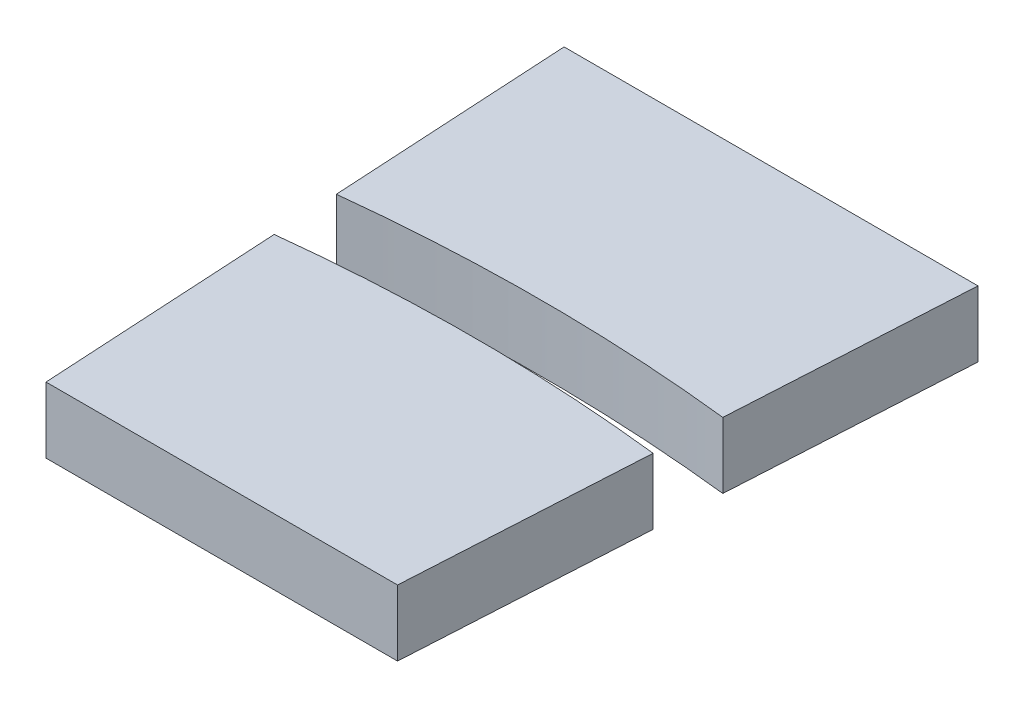
from build123d import *

# Parameters (mm, degrees)
BOSS_EXTRUDE1_DEPTH     = 3
CUT_EXTRUDE1_DEPTH      = 1
CUT_EXTRUDE1_DEPTH_BACK = 4


with BuildPart() as part:
    # Sketch1 → Boss-Extrude1 (new body)
    with BuildSketch(Plane(origin=(0, 0, 0), x_dir=(1, 0, 0), z_dir=(0, 1, 0))):
        Polygon((-9.419602878, 89.5), (-8, 64.5), (0, 64.5), (0, 89.5), align=None)
    boss_extrude1 = extrude(amount=BOSS_EXTRUDE1_DEPTH)

    # Mirror1: Boss-Extrude1 across plane
    add(boss_extrude1.mirror(Plane(origin=(0, 0, 0), x_dir=(0, 0, 1), z_dir=(1, 0, 0))))

    # Sketch2 → Cut-Extrude1 (cut, two sides)
    with BuildSketch(Plane(origin=(0, 3, 0), x_dir=(1, 0, 0), z_dir=(0, 1, 0))) as cut_extrude1_sk:
        with BuildLine():
            Line((-8.625135555, 75.508986463), (-8.795480151, 78.508850004))
            ThreePointArc((-8.795480151, 78.508850004), (0, 79), (8.795480151, 78.508850004))
            Line((8.795480151, 78.508850004), (8.625135555, 75.508986463))
            ThreePointArc((8.625135555, 75.508986463), (0, 76), (-8.625135555, 75.508986463))
        make_face()
    extrude(amount=CUT_EXTRUDE1_DEPTH, mode=Mode.SUBTRACT)
    extrude(cut_extrude1_sk.sketch, amount=-CUT_EXTRUDE1_DEPTH_BACK, mode=Mode.SUBTRACT)


solid = part.part
